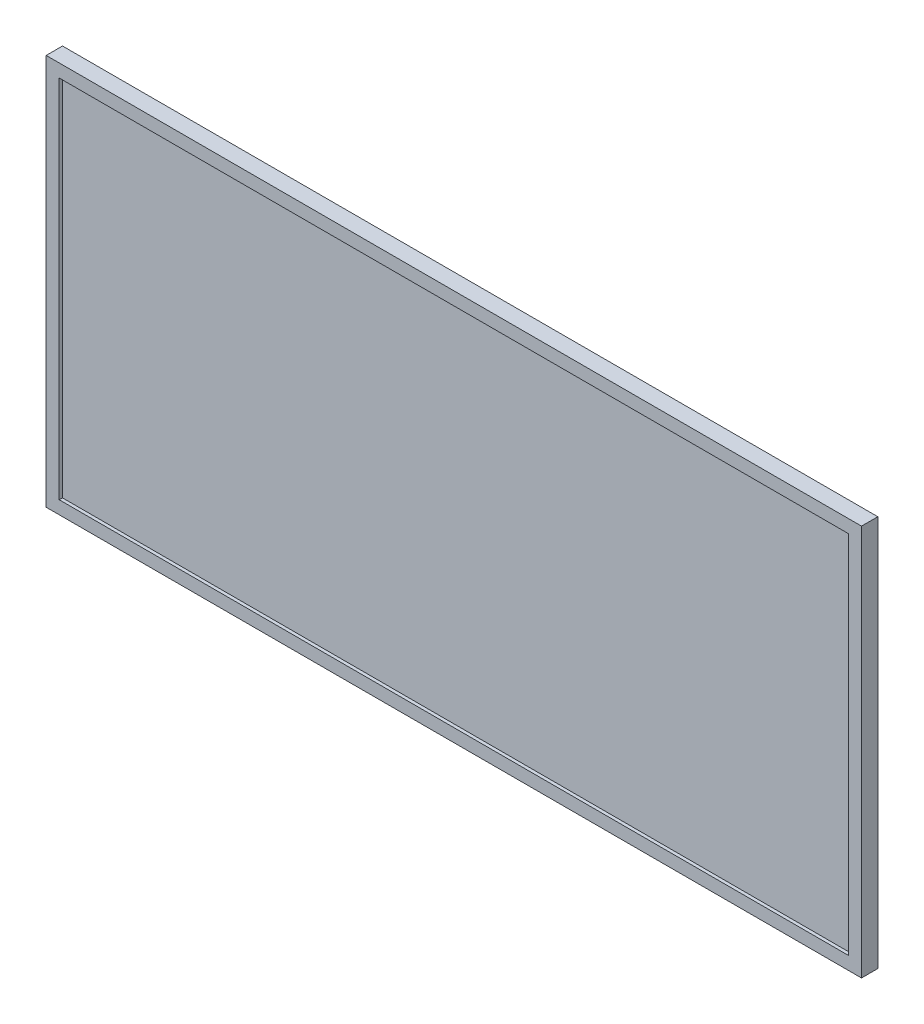
from build123d import *

# Parameters (mm, degrees)
SKETCH_1_W          = 500
SKETCH_1_H          = 240
EXTRUDE_1_DEPTH     = 10
SHELL_1_T           = -8
EXTRUDE_2_DEPTH     = 20
SKETCH_9_R          = 1.65
CUT_EXTRUDE_1_DEPTH = 10


with BuildPart() as part:
    # 草圖1 → 填料-伸長1 (new body)
    with BuildSketch(Plane.XY):
        Rectangle(SKETCH_1_W, SKETCH_1_H)
    extrude(amount=EXTRUDE_1_DEPTH)

    # 薄殼1
    shell_1_openings = [part.faces().sort_by_distance(p)[0] for p in [
        (0, 0, 10),
    ]]
    offset(amount=SHELL_1_T, openings=shell_1_openings, kind=Kind.INTERSECTION)

    # 草圖2 → 填料-伸長2 (add)
    with BuildSketch(Plane(origin=(0, 0, 0), x_dir=(-1, 0, 0), z_dir=(0, 0, -1))):
        with BuildLine():
            Line((-30, -40), (30, -40))
            ThreePointArc((30, -40), (37.071067812, -37.071067812), (40, -30))
            Line((40, -30), (40, 30))
            ThreePointArc((40, 30), (37.071067812, 37.071067812), (30, 40))
            Line((30, 40), (-30, 40))
            ThreePointArc((-30, 40), (-37.071067812, 37.071067812), (-40, 30))
            Line((-40, 30), (-40, -30))
            ThreePointArc((-40, -30), (-37.071067812, -37.071067812), (-30, -40))
        make_face()
    extrude(amount=EXTRUDE_2_DEPTH)

    # 草圖9 → 除料-伸長1 (cut)
    with BuildSketch(Plane(origin=(0, 0, -20), x_dir=(-1, 0, 0), z_dir=(0, 0, -1))):
        Circle(SKETCH_9_R)
    extrude(amount=-CUT_EXTRUDE_1_DEPTH, mode=Mode.SUBTRACT)


solid = part.part
